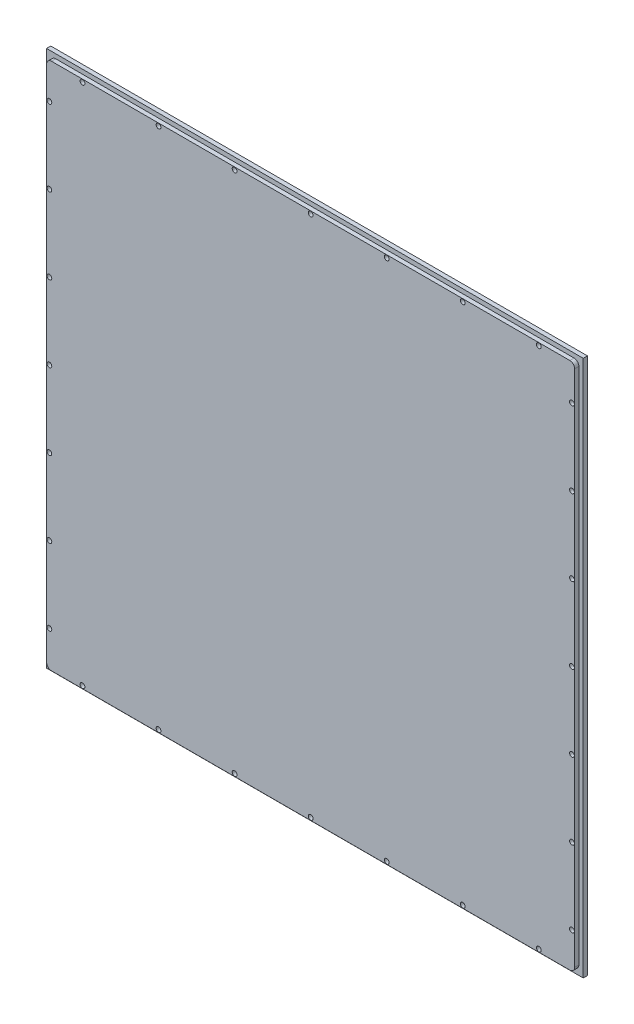
from build123d import *

# Parameters (mm, degrees)
ESQUISSE1_W                                    = 381
ESQUISSE1_H                                    = 381
BOSS_EXTRU_1_DEPTH                             = 3
BOSS_EXTRU_2_DEPTH                             = 3
FRAISAGE_POUR_VIS_T_TE_FRAIS_E_M31_D           = 3.4
FRAISAGE_POUR_VIS_T_TE_FRAIS_E_M31_CSINK_D     = 6.3
FRAISAGE_POUR_VIS_T_TE_FRAIS_E_M31_CSINK_ANGLE = 90


with BuildPart() as part:
    # Esquisse1 → Boss.-Extru.1 (new body)
    with BuildSketch(Plane.XY):
        with Locations((190.5, 190.5)):
            Rectangle(ESQUISSE1_W, ESQUISSE1_H)
    extrude(amount=BOSS_EXTRU_1_DEPTH)

    # Esquisse2 → Boss.-Extru.2 (add)
    with BuildSketch(Plane.XY.offset(3)):
        with BuildLine():
            Line((6.5, 3.1), (374.5, 3.1))
            ThreePointArc((374.5, 3.1), (376.904163056, 4.095836944), (377.9, 6.5))
            Line((377.9, 6.5), (377.9, 374.5))
            ThreePointArc((377.9, 374.5), (376.904163056, 376.904163056), (374.5, 377.9))
            Line((374.5, 377.9), (6.5, 377.9))
            ThreePointArc((6.5, 377.9), (4.095836944, 376.904163056), (3.1, 374.5))
            Line((3.1, 374.5), (3.1, 6.5))
            ThreePointArc((3.1, 6.5), (4.095836944, 4.095836944), (6.5, 3.1))
        make_face()
    extrude(amount=BOSS_EXTRU_2_DEPTH)

    # Fraisage pour vis à tête fraisée M31 (through all)
    with Locations(Plane(origin=(0, 0, 0), x_dir=(-1, 0, 0), z_dir=(0, 0, -1))):
        with Locations((-28.5, 5), (-82.5, 5), (-136.5, 5), (-190.5, 5), (-244.5, 5), (-298.5, 5), (-352.5, 5), (-376, 28.5), (-376, 82.5), (-376, 136.5), (-376, 190.5), (-376, 244.5), (-376, 298.5), (-376, 352.5), (-352.5, 376), (-298.5, 376), (-244.5, 376), (-190.5, 376), (-136.5, 376), (-82.5, 376), (-28.5, 376), (-5, 352.5), (-5, 298.5), (-5, 244.5), (-5, 190.5), (-5, 136.5), (-5, 82.5), (-5, 28.5)):
            CounterSinkHole(FRAISAGE_POUR_VIS_T_TE_FRAIS_E_M31_D / 2, FRAISAGE_POUR_VIS_T_TE_FRAIS_E_M31_CSINK_D / 2, counter_sink_angle=FRAISAGE_POUR_VIS_T_TE_FRAIS_E_M31_CSINK_ANGLE)


solid = part.part
